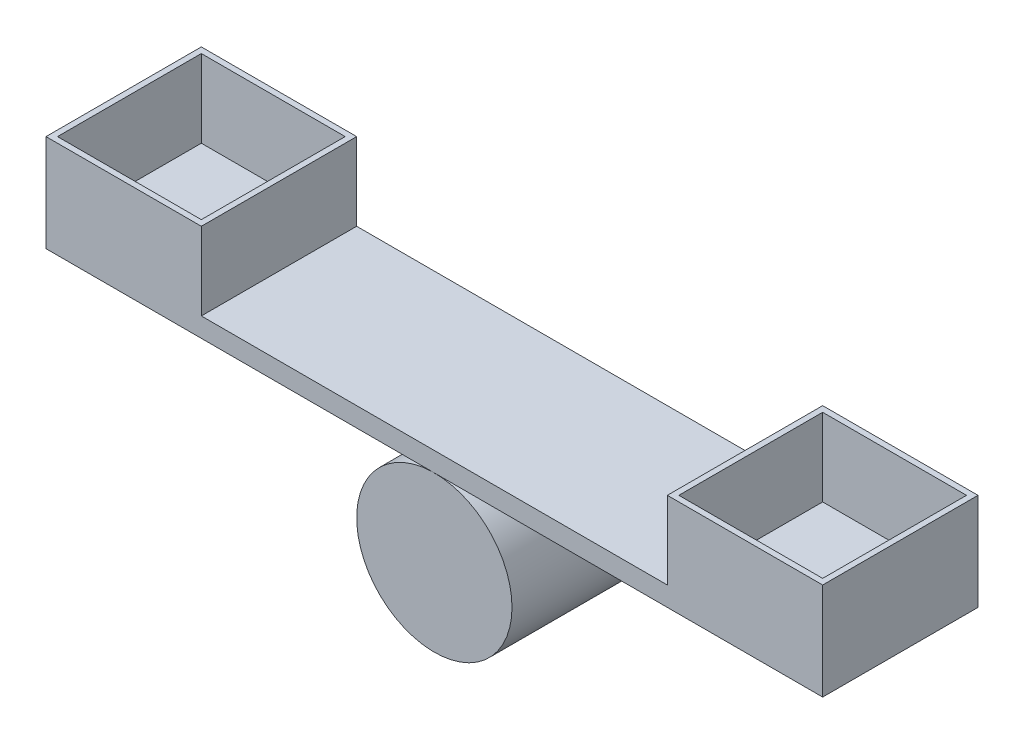
from build123d import *

# Parameters (mm, degrees)
BOSS_EXTRUDE1_DEPTH   = 101.6
SKETCH1_R             = 50.8
BOSS_EXTRUDE1_2_DEPTH = 101.6
SKETCH2_W             = 101.6
SKETCH2_H             = 101.6
SKETCH2_W_2           = 94.085415818
SKETCH2_H_2           = 94.085415818
BOSS_EXTRUDE2_DEPTH   = 50.8


with BuildPart() as part:
    # Sketch1 → Boss-Extrude1 (new body)
    with BuildSketch(Plane.XY):
        Polygon((-254, 63.5), (-254, 50.8), (0, 50.8), (254, 50.8), (254, 63.5), align=None)
    extrude(amount=BOSS_EXTRUDE1_DEPTH)

    # Sketch2 → Boss-Extrude2 (add)
    with BuildSketch(Plane(origin=(0, 63.5, 0), x_dir=(1, 0, 0), z_dir=(0, 1, 0))):
        with Locations((-203.2, -50.8)):
            Rectangle(SKETCH2_W, SKETCH2_H)
        with Locations((-203.2, -50.8)):
            Rectangle(SKETCH2_W_2, SKETCH2_H_2, mode=Mode.SUBTRACT)
        with Locations((203.2, -50.8)):
            Rectangle(SKETCH2_W, SKETCH2_H)
        with Locations((203.2, -50.8)):
            Rectangle(SKETCH2_W_2, SKETCH2_H_2, mode=Mode.SUBTRACT)
    extrude(amount=BOSS_EXTRUDE2_DEPTH)


with BuildPart() as body_2:
    # Sketch1 → Boss-Extrude1 2 (new body)
    with BuildSketch(Plane.XY):
        Circle(SKETCH1_R)
    extrude(amount=BOSS_EXTRUDE1_2_DEPTH)


solid = Compound([part.part, body_2.part])
